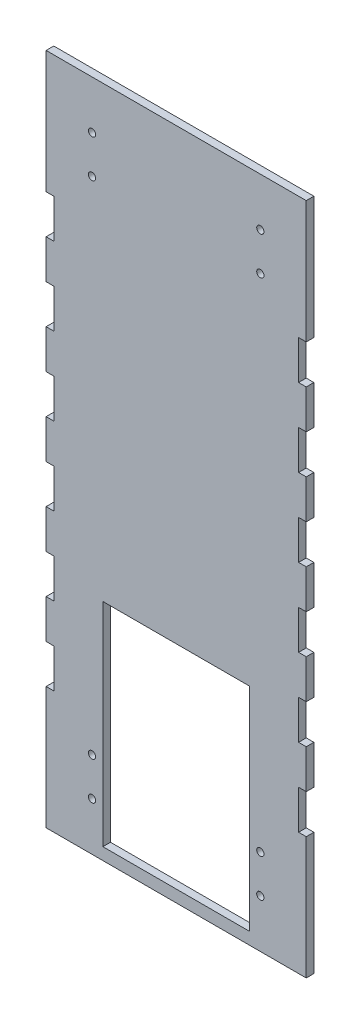
from build123d import *

# Parameters (mm, degrees)
BOSS_EXTRUDE1_DEPTH = 3.175
SKETCH2_R           = 1.5
CUT_EXTRUDE1_DEPTH  = 3.175
SKETCH3_W           = 60.85
SKETCH3_H           = 88.133333333
CUT_EXTRUDE2_DEPTH  = 3.175


with BuildPart() as part:
    # Sketch1 → Boss-Extrude1 (new body)
    with BuildSketch(Plane.XY):
        Polygon((-3.175, 279.4), (-3.175, 228.6), (0, 228.6), (0, 212.436363636), (-3.175, 212.436363636), (-3.175, 196.272727273), (0, 196.272727273), (0, 180.109090909), (-3.175, 180.109090909), (-3.175, 163.945454545), (0, 163.945454545), (0, 147.781818182), (-3.175, 147.781818182), (-3.175, 131.618181818), (0, 131.618181818), (0, 115.454545455), (-3.175, 115.454545455), (-3.175, 99.290909091), (0, 99.290909091), (0, 83.127272727), (-3.175, 83.127272727), (-3.175, 66.963636364), (0, 66.963636364), (0, 50.8), (-3.175, 50.8), (-3.175, 0), (104.775, 0), (104.775, 50.8), (101.6, 50.8), (101.6, 66.963636364), (104.775, 66.963636364), (104.775, 83.127272727), (101.6, 83.127272727), (101.6, 99.290909091), (104.775, 99.290909091), (104.775, 115.454545455), (101.6, 115.454545455), (101.6, 131.618181818), (104.775, 131.618181818), (104.775, 147.781818182), (101.6, 147.781818182), (101.6, 163.945454545), (104.775, 163.945454545), (104.775, 180.109090909), (101.6, 180.109090909), (101.6, 196.272727273), (104.775, 196.272727273), (104.775, 212.436363636), (101.6, 212.436363636), (101.6, 228.6), (104.775, 228.6), (104.775, 279.4), align=None)
    extrude(amount=BOSS_EXTRUDE1_DEPTH)

    # Sketch2 → Cut-Extrude1 (cut)
    with BuildSketch(Plane.XY.offset(3.175)):
        with Locations((15.875, 20)):
            Circle(SKETCH2_R)
        with Locations((15.875, 35.75)):
            Circle(SKETCH2_R)
        with Locations((15.875, 243.65)):
            Circle(SKETCH2_R)
        with Locations((15.875, 259.4)):
            Circle(SKETCH2_R)
        with Locations((85.725, 259.4)):
            Circle(SKETCH2_R)
        with Locations((85.725, 243.65)):
            Circle(SKETCH2_R)
        with Locations((85.725, 35.75)):
            Circle(SKETCH2_R)
        with Locations((85.725, 20)):
            Circle(SKETCH2_R)
    extrude(amount=-CUT_EXTRUDE1_DEPTH, mode=Mode.SUBTRACT)

    # Sketch3 → Cut-Extrude2 (cut)
    with BuildSketch(Plane.XY.offset(3.175)):
        with Locations((50.8, 49.066666667)):
            Rectangle(SKETCH3_W, SKETCH3_H)
    extrude(amount=-CUT_EXTRUDE2_DEPTH, mode=Mode.SUBTRACT)


solid = part.part
